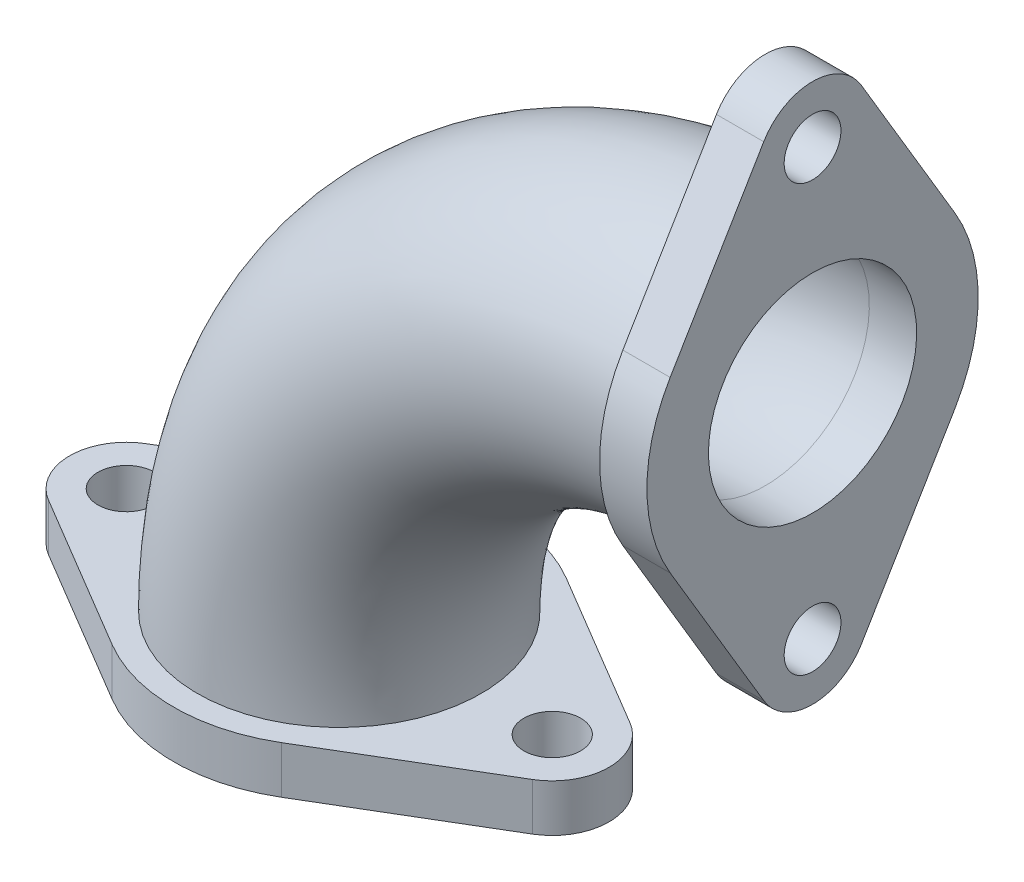
from build123d import *

# Parameters (mm, degrees)
SWEEP_THIN1_PROFILE_R   = 15
SWEEP_THIN1_PROFILE_R_2 = 11
SKETCH65_R              = 11
SKETCH65_R_2            = 3
BOSS_EXTRUDE1_DEPTH     = 5
SKETCH66_R              = 11
SKETCH66_R_2            = 3
BOSS_EXTRUDE2_DEPTH     = 5


with BuildPart() as part:
    # Sweep-Thin1: sweep along a path in Sketch1
    with BuildLine(Plane.XY) as sweep_thin1_path:
        ThreePointArc((-45, 0), (-31.819805153, 31.819805153), (0, 45))
    # Sweep-Thin1 profile (on start of the path) → Sweep-Thin1 (sweep)
    with BuildSketch(Plane(origin=(-45, 0, 0), x_dir=(1, 0, 0), z_dir=(0, 1, 0))):
        Circle(SWEEP_THIN1_PROFILE_R)
        Circle(SWEEP_THIN1_PROFILE_R_2, mode=Mode.SUBTRACT)
    sweep(path=sweep_thin1_path.line)

    # Sketch65 → Boss-Extrude1 (add)
    with BuildSketch(Plane(origin=(0, 0, 0), x_dir=(0, 0, -1), z_dir=(1, 0, 0))):
        with BuildLine():
            Line((-5.157087895, 70.566666667), (-15.04150636, 53.944444444))
            ThreePointArc((-15.04150636, 53.944444444), (-17.5, 45), (-15.04150636, 36.055555556))
            Line((-15.04150636, 36.055555556), (-5.157087895, 19.433333333))
            ThreePointArc((-5.157087895, 19.433333333), (0, 16.5), (5.157087895, 19.433333333))
            Line((5.157087895, 19.433333333), (15.04150636, 36.055555556))
            ThreePointArc((15.04150636, 36.055555556), (17.5, 45), (15.04150636, 53.944444444))
            Line((15.04150636, 53.944444444), (5.157087895, 70.566666667))
            ThreePointArc((5.157087895, 70.566666667), (0, 73.5), (-5.157087895, 70.566666667))
        make_face()
        with Locations(Location((0, 45, 0), (0, 0, 90))):
            Circle(SKETCH65_R, mode=Mode.SUBTRACT)
        with Locations(Location((0, 67.5, 0), (0, 0, 90))):
            Circle(SKETCH65_R_2, mode=Mode.SUBTRACT)
        with Locations(Location((0, 22.5, 0), (0, 0, 90))):
            Circle(SKETCH65_R_2, mode=Mode.SUBTRACT)
    extrude(amount=BOSS_EXTRUDE1_DEPTH)

    # Sketch66 → Boss-Extrude2 (add)
    with BuildSketch(Plane.XZ):
        with BuildLine():
            Line((-53.944444444, 15.04150636), (-70.566666667, 5.157087895))
            ThreePointArc((-70.566666667, 5.157087895), (-73.5, 0), (-70.566666667, -5.157087895))
            Line((-70.566666667, -5.157087895), (-53.944444444, -15.04150636))
            ThreePointArc((-53.944444444, -15.04150636), (-45, -17.5), (-36.055555556, -15.04150636))
            Line((-36.055555556, -15.04150636), (-19.433333333, -5.157087895))
            ThreePointArc((-19.433333333, -5.157087895), (-16.5, 0), (-19.433333333, 5.157087895))
            Line((-19.433333333, 5.157087895), (-36.055555556, 15.04150636))
            ThreePointArc((-36.055555556, 15.04150636), (-45, 17.5), (-53.944444444, 15.04150636))
        make_face()
        with Locations(Location((-45, 0, 0), (0, 0, 180))):
            Circle(SKETCH66_R, mode=Mode.SUBTRACT)
        with Locations((-67.5, 0)):
            Circle(SKETCH66_R_2, mode=Mode.SUBTRACT)
        with Locations((-22.5, 0)):
            Circle(SKETCH66_R_2, mode=Mode.SUBTRACT)
    extrude(amount=BOSS_EXTRUDE2_DEPTH)


solid = part.part
